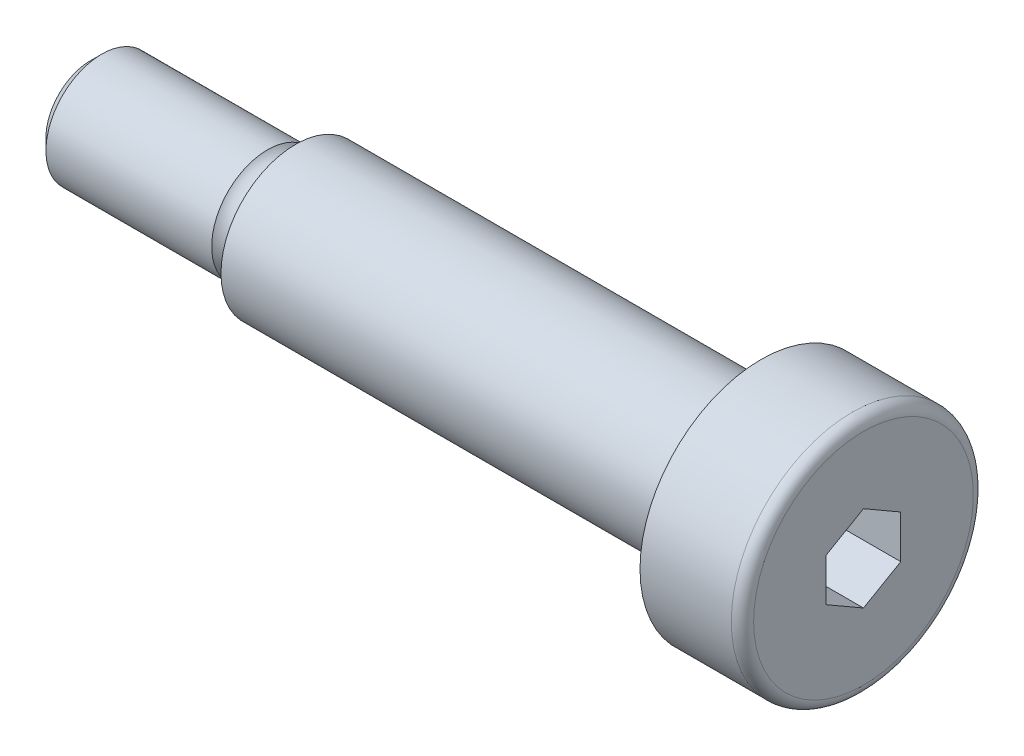
from build123d import *

# Parameters (mm, degrees)
ZAOKR_GLENIE1_R            = 0.6
SFAZOWANIE1_SIZE           = 0.6
WYTNIJ_WYCI_GNI_CIE1_DEPTH = 5


with BuildPart() as part:
    # ruba parametryczna → Obrót1 (revolve)
    with BuildSketch(Plane.XY):
        Polygon((0, 0), (0, 6.5), (-5.5, 6.5), (-5.5, 4), (-30.5, 4), (-30.5, 3), (-41.5, 3), (-41.5, 0), align=None)
    revolve(axis=Axis((0, 0, 0), (1, 0, 0)))

    # Zaokrąglenie1
    zaokr_glenie1_edges = [part.edges().sort_by_distance(p)[0] for p in [
        (0, -6.5, 0),
    ]]
    fillet(zaokr_glenie1_edges, radius=ZAOKR_GLENIE1_R)

    # Sfazowanie1
    sfazowanie1_edges = [part.edges().sort_by_distance(p)[0] for p in [
        (-41.5, -3, 0),
    ]]
    chamfer(sfazowanie1_edges, length=SFAZOWANIE1_SIZE)

    # Szkic2 → Wytnij-wyciągnięcie1 (cut)
    with BuildSketch(Plane(origin=(0, 0, 0), x_dir=(0, 0, -1), z_dir=(1, 0, 0))):
        Polygon((-2, -1.154700538), (0, -2.309401077), (2, -1.154700538), (2, 1.154700538), (0, 2.309401077), (-2, 1.154700538), align=None)
    extrude(amount=-WYTNIJ_WYCI_GNI_CIE1_DEPTH, mode=Mode.SUBTRACT)

    # Szkic3 → Wycięcie-obrót1 (revolve, cut)
    with BuildSketch(Plane(origin=(0, 0, 0), x_dir=(1, 0, 0), z_dir=(0, 1, 0))):
        with BuildLine():
            Line((-32, -3), (-30.5, -3))
            ThreePointArc((-30.5, -3), (-31.25, -2.661437828), (-32, -3))
        make_face()
    revolve(axis=Axis((3.805158027, 0, 0), (-1, 0, 0)), mode=Mode.SUBTRACT)


solid = part.part
